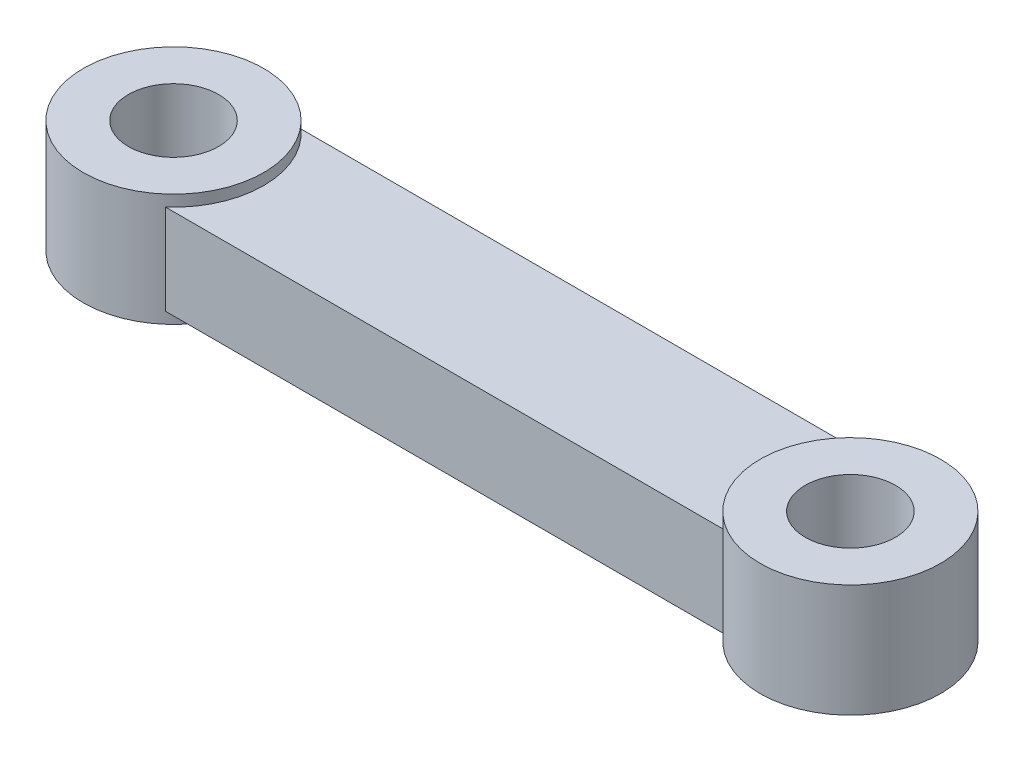
from build123d import *

# Parameters (mm, degrees)
SKETCH_1_R        = 8
SKETCH_1_R_2      = 4
EXTRUDE_1_DEPTH   = 10
EXTRUDE_1_2_DEPTH = 10
EXTRUDE_START     = 1
EXTRUDE_2_DEPTH   = 8


with BuildPart() as part:
    # 草图1 → 凸台-拉伸1 (new body)
    with BuildSketch(Plane(origin=(0, 0, 0), x_dir=(1, 0, 0), z_dir=(0, 1, 0))):
        Circle(SKETCH_1_R)
        Circle(SKETCH_1_R_2, mode=Mode.SUBTRACT)
    extrude(amount=EXTRUDE_1_DEPTH)



with BuildPart() as body_2:
    # 草图1 → Extrude 1 2 (new body)
    with BuildSketch(Plane(origin=(0, 0, 0), x_dir=(1, 0, 0), z_dir=(0, 1, 0))):
        with Locations((60, 0)):
            Circle(SKETCH_1_R)
        with Locations((60, 0)):
            Circle(SKETCH_1_R_2, mode=Mode.SUBTRACT)
    extrude(amount=EXTRUDE_1_2_DEPTH)


with BuildPart() as part_1:
    add(part.part)

    add(body_2.part)  # 凸台-拉伸2 merges body 2
    # 草图2 → 凸台-拉伸2 (add)
    with BuildSketch(Plane(origin=(0, 0, 0), x_dir=(1, 0, 0), z_dir=(0, 1, 0)).offset(EXTRUDE_START)):
        with BuildLine():
            Line((5.291502622, -6), (54.708497378, -6))
            ThreePointArc((54.708497378, -6), (52, 0), (54.708497378, 6))
            Line((54.708497378, 6), (5.291502622, 6))
            ThreePointArc((5.291502622, 6), (8, 0), (5.291502622, -6))
        make_face()
    extrude(amount=EXTRUDE_2_DEPTH)


solid = part_1.part
